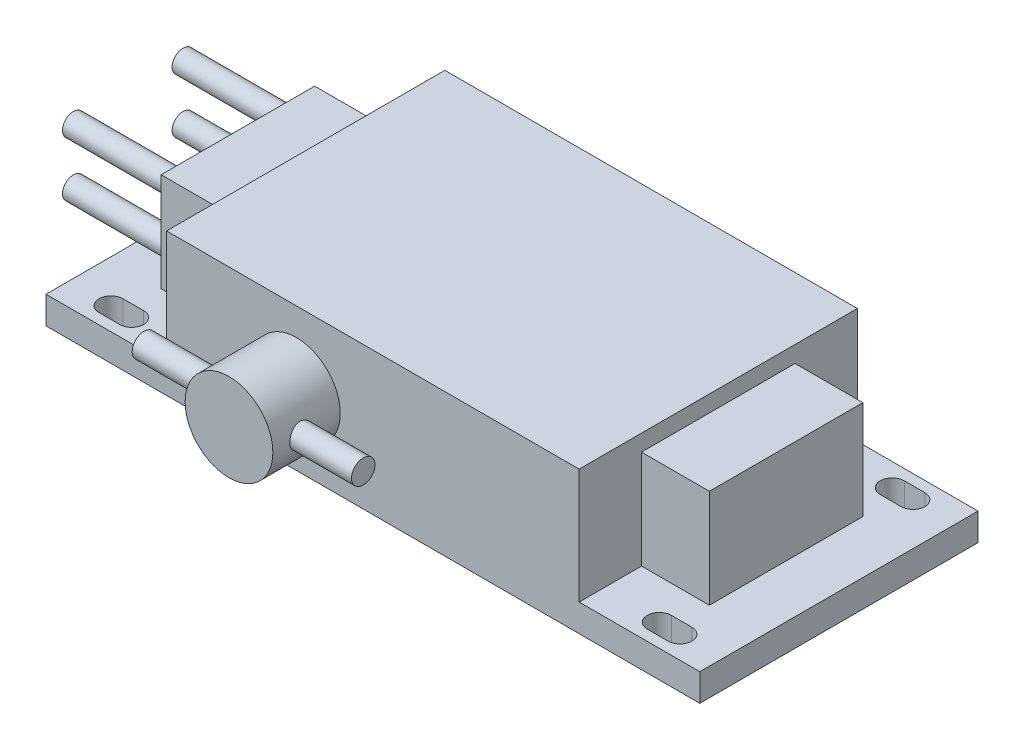
from build123d import *

# Parameters (mm, degrees)
SKETCH1_W           = 119.25
SKETCH1_H           = 50.75
EXTRUDE1_DEPTH      = 5
SKETCH2_W           = 75.25
SKETCH2_H           = 50.75
EXTRUDE2_DEPTH      = 21
SKETCH3_W           = 100
SKETCH3_H           = 28
EXTRUDE3_DEPTH      = 18
SKETCH4_R           = 8
EXTRUDE4_DEPTH      = 12.3
EXTRUDE5_START      = -52.32
SKETCH5_R           = 2.144071556
EXTRUDE5_DEPTH      = 20
EXTRUDE5_DEPTH_BACK = 20
SKETCH6_R           = 2
EXTRUDE6_DEPTH      = 20


with BuildPart() as part:
    # Sketch1 → Extrude1 (new body)
    with BuildSketch(Plane(origin=(0, 0, 0), x_dir=(1, 0, 0), z_dir=(0, 1, 0))):
        with Locations((59.625, 0)):
            Rectangle(SKETCH1_W, SKETCH1_H)
        with BuildLine():
            Line((107.74, 23.435), (111.51, 23.435))
            ThreePointArc((111.51, 23.435), (113.695, 21.25), (111.51, 19.065))
            Line((111.51, 19.065), (107.74, 19.065))
            ThreePointArc((107.74, 19.065), (105.555, 21.25), (107.74, 23.435))
        make_face(mode=Mode.SUBTRACT)
        with BuildLine():
            Line((107.74, -19.065), (111.51, -19.065))
            ThreePointArc((111.51, -19.065), (113.695, -21.25), (111.51, -23.435))
            Line((111.51, -23.435), (107.74, -23.435))
            ThreePointArc((107.74, -23.435), (105.555, -21.25), (107.74, -19.065))
        make_face(mode=Mode.SUBTRACT)
        with BuildLine():
            Line((7.74, -19.065), (11.51, -19.065))
            ThreePointArc((11.51, -19.065), (13.695, -21.25), (11.51, -23.435))
            Line((11.51, -23.435), (7.74, -23.435))
            ThreePointArc((7.74, -23.435), (5.555, -21.25), (7.74, -19.065))
        make_face(mode=Mode.SUBTRACT)
        with BuildLine():
            Line((7.74, 23.435), (11.51, 23.435))
            ThreePointArc((11.51, 23.435), (13.695, 21.25), (11.51, 19.065))
            Line((11.51, 19.065), (7.74, 19.065))
            ThreePointArc((7.74, 19.065), (5.555, 21.25), (7.74, 23.435))
        make_face(mode=Mode.SUBTRACT)
    extrude(amount=EXTRUDE1_DEPTH)

    # Sketch2 → Extrude2 (add)
    with BuildSketch(Plane(origin=(0, 5, 0), x_dir=(1, 0, 0), z_dir=(0, 1, 0))):
        with Locations((59.625, 0)):
            Rectangle(SKETCH2_W, SKETCH2_H)
    extrude(amount=EXTRUDE2_DEPTH)

    # Sketch3 → Extrude3 (add)
    with BuildSketch(Plane(origin=(0, 5, 0), x_dir=(1, 0, 0), z_dir=(0, 1, 0))):
        with Locations((59.625, 0)):
            Rectangle(SKETCH3_W, SKETCH3_H)
    extrude(amount=EXTRUDE3_DEPTH)

    # Sketch4 → Extrude4 (add)
    with BuildSketch(Plane.XY.offset(25.375)):
        with Locations((45.677401857, 13)):
            Circle(SKETCH4_R)
    extrude(amount=EXTRUDE4_DEPTH)

    # Sketch5 → Extrude5 (add, two sides)
    with BuildSketch(Plane(origin=(97.25, 0, 0), x_dir=(0, 0, -1), z_dir=(1, 0, 0)).offset(EXTRUDE5_START)) as extrude5_sk:
        with Locations((-32.438828155, 13)):
            Circle(SKETCH5_R)
    extrude(amount=EXTRUDE5_DEPTH)
    extrude(extrude5_sk.sketch, amount=-EXTRUDE5_DEPTH_BACK)

    # Sketch6 → Extrude6 (add)
    with BuildSketch(Plane.ZY.offset(-9.625)):
        with Locations((-10, 9)):
            Circle(SKETCH6_R)
        with Locations((-10, 19)):
            Circle(SKETCH6_R)
        with Locations((10, 9)):
            Circle(SKETCH6_R)
        with Locations((10, 19)):
            Circle(SKETCH6_R)
    extrude(amount=EXTRUDE6_DEPTH)


solid = part.part
